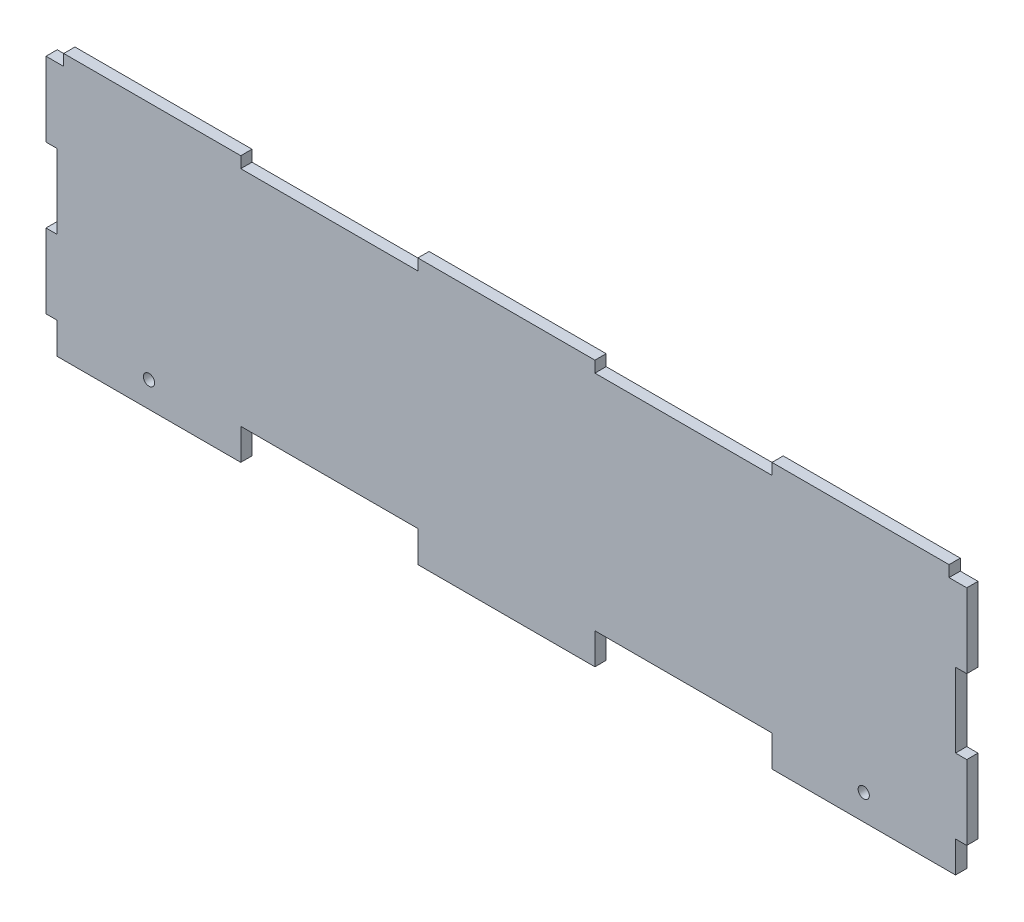
from build123d import *

# Parameters (mm, degrees)
SKETCH1_R           = 1.575
BOSS_EXTRUDE1_DEPTH = 3.175


with BuildPart() as part:
    # Sketch1 → Boss-Extrude1 (new body)
    with BuildSketch(Plane.XY):
        Polygon((55, 75), (5, 75), (5, 71.825), (0, 71.825), (0, 50.825), (3.175, 50.825), (3.175, 29.825), (0, 29.825), (0, 8.825), (3.175, 8.825), (3.175, 0), (55, 0), (55, 8.825), (105, 8.825), (105, 0), (155, 0), (155, 8.825), (205, 8.825), (205, 0), (256.825, 0), (256.825, 8.825), (260, 8.825), (260, 29.825), (256.825, 29.825), (256.825, 50.825), (260, 50.825), (260, 71.825), (255, 71.825), (255, 75), (205, 75), (205, 71.825), (155, 71.825), (155, 75), (105, 75), (105, 71.825), (55, 71.825), align=None)
        with Locations((29.0875, 7.2375)):
            Circle(SKETCH1_R, mode=Mode.SUBTRACT)
        with Locations((230.9125, 7.2375)):
            Circle(SKETCH1_R, mode=Mode.SUBTRACT)
    extrude(amount=BOSS_EXTRUDE1_DEPTH)


solid = part.part
